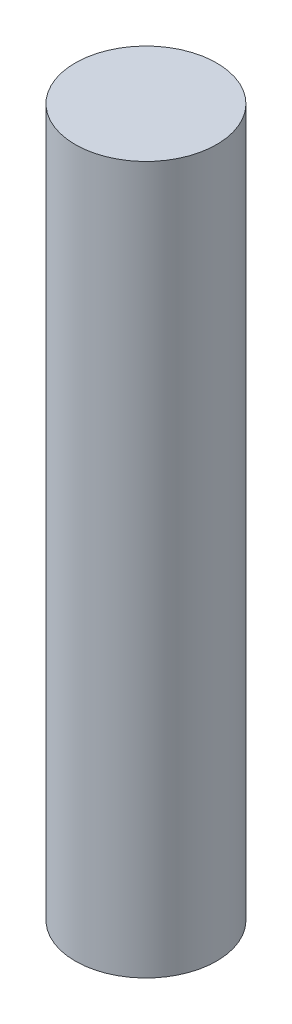
from build123d import *

# Parameters (mm, degrees)
SKETCH1_R           = 3
BOSS_EXTRUDE1_DEPTH = 30


with BuildPart() as part:
    # Sketch1 → Boss-Extrude1 (new body)
    with BuildSketch(Plane(origin=(0, 0, 0), x_dir=(1, 0, 0), z_dir=(0, 1, 0))):
        Circle(SKETCH1_R)
    extrude(amount=BOSS_EXTRUDE1_DEPTH)


solid = part.part
